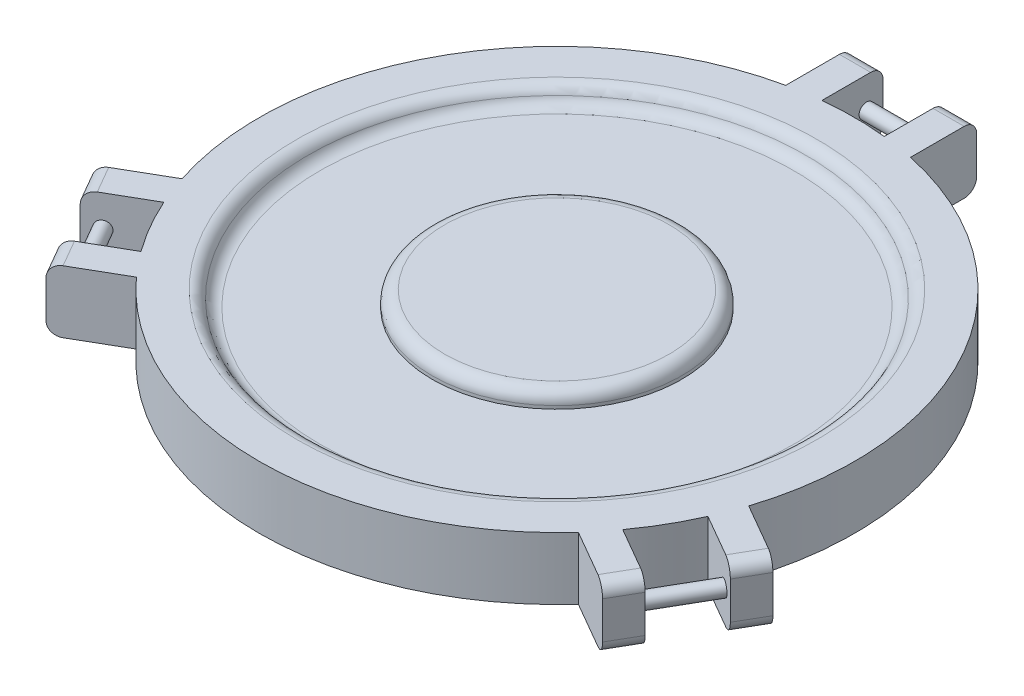
from build123d import *

# Parameters (mm, degrees)
BOSS_EXTRUDE1_DEPTH = 50
SKETCH2_R           = 200
CUT_EXTRUDE1_DEPTH  = 12.5
SKETCH3_R           = 100
BOSS_EXTRUDE2_DEPTH = 12.5
FILLET1_R           = 10
FILLET8_R           = 10
FILLET10_R          = 10
FILLET11_R          = 10
SKETCH4_R           = 6
BOSS_EXTRUDE3_DEPTH = 36
CIRPATTERN1_COUNT   = 3


with BuildPart() as part:
    # Sketch1 → Boss-Extrude1 (new body)
    with BuildSketch(Plane(origin=(0, 0, 0), x_dir=(1, 0, 0), z_dir=(0, 1, 0))):
        with BuildLine():
            Line((177.17937854, -160.029588814), (223.117233569, -186.551821781))
            Line((223.117233569, -186.551821781), (235.617233569, -164.901186686))
            Line((235.617233569, -164.901186686), (193.127700242, -140.369843182))
            ThreePointArc((193.127700242, -140.369843182), (206.764361308, -119.37545966), (218.127700242, -97.068572993))
            Line((218.127700242, -97.068572993), (260.617233569, -121.599916497))
            Line((260.617233569, -121.599916497), (273.117233569, -99.949281403))
            Line((273.117233569, -99.949281403), (227.17937854, -73.427048436))
            ThreePointArc((227.17937854, -73.427048436), (206.764361308, 119.37545966), (50, 233.45663725))
            Line((50, 233.45663725), (50, 286.501103184))
            Line((50, 286.501103184), (25, 286.501103184))
            Line((25, 286.501103184), (25, 237.438416176))
            ThreePointArc((25, 237.438416176), (0, 238.75091932), (-25, 237.438416176))
            Line((-25, 237.438416176), (-25, 286.501103184))
            Line((-25, 286.501103184), (-50, 286.501103184))
            Line((-50, 286.501103184), (-50, 233.45663725))
            ThreePointArc((-50, 233.45663725), (-206.764361308, 119.37545966), (-227.17937854, -73.427048436))
            Line((-227.17937854, -73.427048436), (-273.117233569, -99.949281403))
            Line((-273.117233569, -99.949281403), (-260.617233569, -121.599916497))
            Line((-260.617233569, -121.599916497), (-218.127700242, -97.068572993))
            ThreePointArc((-218.127700242, -97.068572993), (-206.764361308, -119.37545966), (-193.127700242, -140.369843182))
            Line((-193.127700242, -140.369843182), (-235.617233569, -164.901186686))
            Line((-235.617233569, -164.901186686), (-223.117233569, -186.551821781))
            Line((-223.117233569, -186.551821781), (-177.17937854, -160.029588814))
            ThreePointArc((-177.17937854, -160.029588814), (0, -238.75091932), (177.17937854, -160.029588814))
        make_face()
    extrude(amount=BOSS_EXTRUDE1_DEPTH)

    # Sketch2 → Cut-Extrude1 (cut)
    with BuildSketch(Plane(origin=(0, 50, 0), x_dir=(1, 0, 0), z_dir=(0, 1, 0))):
        Circle(SKETCH2_R)
    extrude(amount=-CUT_EXTRUDE1_DEPTH, mode=Mode.SUBTRACT)

    # Sketch3 → Boss-Extrude2 (add)
    with BuildSketch(Plane(origin=(0, 37.5, 0), x_dir=(1, 0, 0), z_dir=(0, 1, 0))):
        Circle(SKETCH3_R)
    extrude(amount=BOSS_EXTRUDE2_DEPTH)

    # Fillet1
    fillet1_edges = [part.edges().sort_by_distance(p)[0] for p in [
        (-37.5, 50, -286.501103184),
        (37.5, 0, -286.501103184),
        (266.867233569, 0, 110.77459895),
        (229.367233569, 0, 175.726504234),
        (-229.367233569, 0, 175.726504234),
        (-266.867233569, 50, 110.77459895),
        (-266.867233569, 0, 110.77459895),
        (-37.5, 0, -286.501103184),
        (-229.367233569, 50, 175.726504234),
        (229.367233569, 50, 175.726504234),
        (266.867233569, 50, 110.77459895),
        (37.5, 50, -286.501103184),
    ]]
    fillet(fillet1_edges, radius=FILLET1_R)

    # Fillet8
    fillet8_edges = [part.edges().sort_by_distance(p)[0] for p in [
        (-100, 50, 0),
    ]]
    fillet(fillet8_edges, radius=FILLET8_R)

    # Fillet10
    fillet10_edges = [part.edges().sort_by_distance(p)[0] for p in [
        (-200, 37.5, 0),
    ]]
    fillet(fillet10_edges, radius=FILLET10_R)

    # Fillet11
    fillet11_edges = [part.edges().sort_by_distance(p)[0] for p in [
        (-200, 50, 0),
    ]]
    fillet(fillet11_edges, radius=FILLET11_R)

    # Sketch4 → Boss-Extrude3 (add, symmetric)
    with BuildSketch(Plane(origin=(0, 0, 0), x_dir=(0, 0, -1), z_dir=(1, 0, 0))):
        with Locations((273.2399867, 25)):
            Circle(SKETCH4_R)
    boss_extrude3 = extrude(amount=BOSS_EXTRUDE3_DEPTH, both=True)

    # CirPattern1: Boss-Extrude3 ×3 about axis
    cirpattern1_axis = Axis((0, 50, 0), (0, -1, 0))
    for i in range(1, CIRPATTERN1_COUNT):
        add(boss_extrude3.rotate(cirpattern1_axis, i * 360 / CIRPATTERN1_COUNT))


solid = part.part
